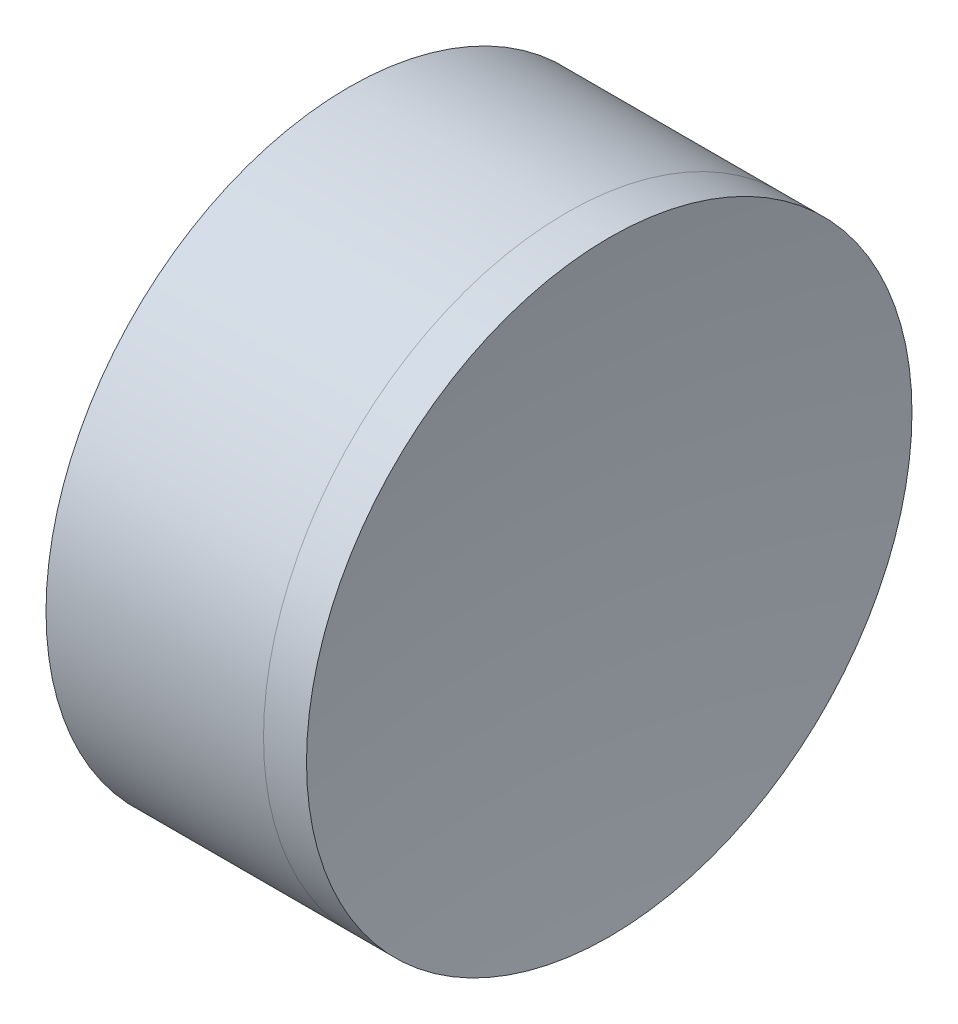
from build123d import *


with BuildPart() as part:
    # 草图1 one side → 旋转1 (revolve)
    with BuildSketch(Plane(origin=(0, 0, 0), x_dir=(1, 0, 0), z_dir=(0, 1, 0)), mode=Mode.PRIVATE) as revolve_1_sk:
        with BuildLine():
            Line((237.082883701, 12.5), (228.102028769, 12.5))
            ThreePointArc((228.102028769, 12.5), (230.055817718, 6.385236467), (230.716408041, 0))
            Line((230.716408041, 0), (233.716408041, 0))
            ThreePointArc((233.716408041, 0), (234.572758497, 6.472695698), (237.082883701, 12.5))
        make_face()
    revolve(revolve_1_sk.sketch.rotate(Axis((-0.816062176, 0, 0), (1, 0, 0)), 180), axis=Axis((-0.816062176, 0, 0), (1, 0, 0)))  # turned: the seam where the file's is


with BuildPart() as body_2:
    # 草图2 one side → 旋转3 (revolve)
    with BuildSketch(Plane(origin=(0, 0, 0), x_dir=(1, 0, 0), z_dir=(0, 1, 0)), mode=Mode.PRIVATE) as revolve_3_sk:
        with BuildLine():
            Line((238.857154578, 12.5), (237.082883701, 12.5))
            ThreePointArc((237.082883701, 12.5), (234.572758497, 6.472695698), (233.716408041, 0))
            Line((233.716408041, 0), (237.936408041, 0))
            ThreePointArc((237.936408041, 0), (238.166906065, 6.266932547), (238.857154578, 12.5))
        make_face()
    revolve(revolve_3_sk.sketch.rotate(Axis((228.102028769, 0, 0), (1, 0, 0)), 180), axis=Axis((228.102028769, 0, 0), (1, 0, 0)))  # turned: the seam where the file's is


solid = Compound([part.part, body_2.part])
